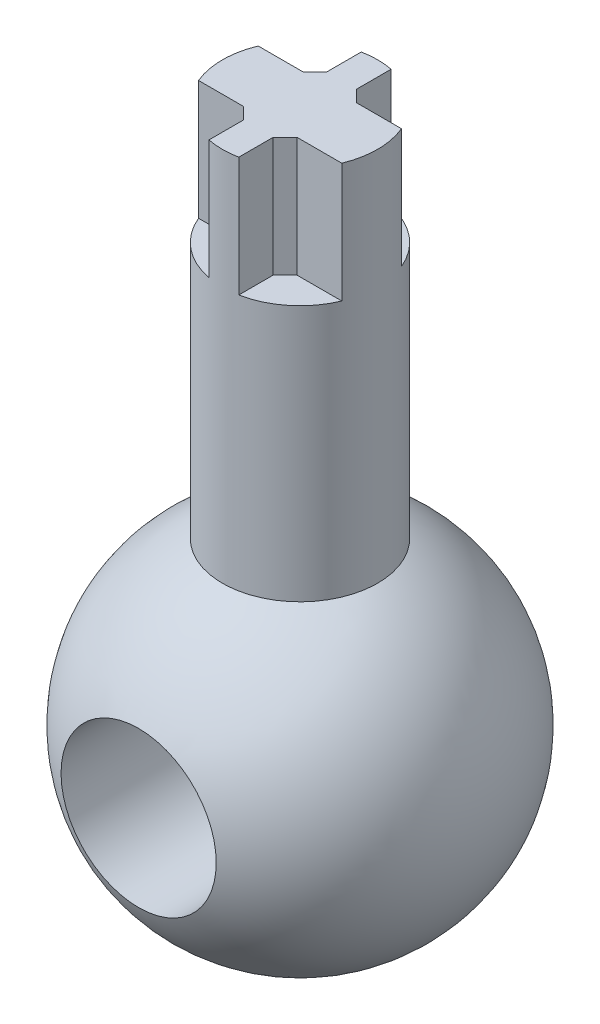
from build123d import *

# Parameters (mm, degrees)
SKETCH_S2_R              = 6.5
EXTRUDE_2_DEPTH          = 45
CUT_EXTRUDE_3_DEPTH      = 10
CHAMFER_4_SIZE           = 1
SKETCH_S5_R              = 6.5
CUT_EXTRUDE_5_DEPTH      = 16
CUT_EXTRUDE_5_DEPTH_BACK = 16


with BuildPart() as part:
    # Sketch s1 → Revolve 1 (revolve)
    with BuildSketch(Plane.XY):
        with BuildLine():
            Line((-15, 0), (15, 0))
            ThreePointArc((15, 0), (0, 15), (-15, 0))
        make_face()
    revolve(axis=Axis((-56.6721202, 0, 0), (1, 0, 0)))

    # Sketch s2 → Extrude 2 (add)
    with BuildSketch(Plane(origin=(0, 0, 0), x_dir=(1, 0, 0), z_dir=(0, 1, 0))):
        Circle(SKETCH_S2_R)
    extrude(amount=EXTRUDE_2_DEPTH)

    # Sketch s3 → Cut-Extrude 3 (cut)
    with BuildSketch(Plane(origin=(0, 45, 0), x_dir=(-1, 0, 0), z_dir=(0, 1, 0))):
        with BuildLine():
            Line((-1.25, -6.378675411), (-1.25, -2.5))
            Line((-1.25, -2.5), (-6, -2.5))
            ThreePointArc((-6, -2.5), (-4.111162334, -5.034713921), (-1.25, -6.378675411))
        make_face()
        with BuildLine():
            Line((1.25, -6.378675411), (1.25, -2.5))
            Line((1.25, -2.5), (6, -2.5))
            ThreePointArc((6, -2.5), (4.111162334, -5.034713921), (1.25, -6.378675411))
        make_face()
        with BuildLine():
            Line((-6, 2.5), (-1.25, 2.5))
            Line((-1.25, 2.5), (-1.25, 6.378675411))
            ThreePointArc((-1.25, 6.378675411), (-4.111162334, 5.034713921), (-6, 2.5))
        make_face()
        with BuildLine():
            Line((1.25, 2.5), (1.25, 6.378675411))
            ThreePointArc((1.25, 6.378675411), (4.111162334, 5.034713921), (6, 2.5))
            Line((6, 2.5), (1.25, 2.5))
        make_face()
    extrude(amount=-CUT_EXTRUDE_3_DEPTH, mode=Mode.SUBTRACT)

    # Chamfer 4
    chamfer_4_edges = [part.edges().sort_by_distance(p)[0] for p in [
        (-1.25, 40, -2.5),
        (-1.25, 40, 2.5),
        (1.25, 40, -2.5),
        (1.25, 40, 2.5),
    ]]
    chamfer(chamfer_4_edges, length=CHAMFER_4_SIZE)

    # Sketch s5 → Cut-Extrude 5 (cut, two sides)
    with BuildSketch(Plane.XY) as cut_extrude_5_sk:
        Circle(SKETCH_S5_R)
    extrude(amount=CUT_EXTRUDE_5_DEPTH, mode=Mode.SUBTRACT)
    extrude(cut_extrude_5_sk.sketch, amount=-CUT_EXTRUDE_5_DEPTH_BACK, mode=Mode.SUBTRACT)


solid = part.part
